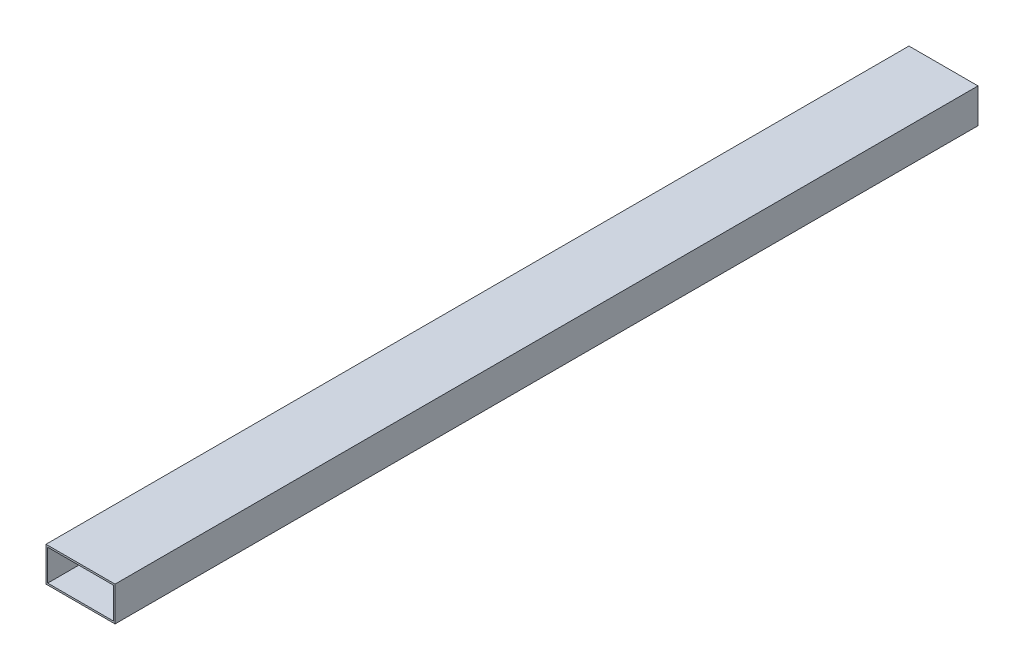
from build123d import *

# Parameters (mm, degrees)
SKETCH1_W           = 40
SKETCH1_H           = 20
BOSS_EXTRUDE1_DEPTH = 500
SKETCH2_W           = 38
SKETCH2_H           = 18
CUT_EXTRUDE1_DEPTH  = 501


with BuildPart() as part:
    # Sketch1 → Boss-Extrude1 (new body)
    with BuildSketch(Plane.XY):
        Rectangle(SKETCH1_W, SKETCH1_H)
    extrude(amount=BOSS_EXTRUDE1_DEPTH)

    # Sketch2 → Cut-Extrude1 (cut, through all)
    with BuildSketch(Plane.XY.offset(500)):
        Rectangle(SKETCH2_W, SKETCH2_H)
    extrude(amount=-CUT_EXTRUDE1_DEPTH, mode=Mode.SUBTRACT)


solid = part.part
